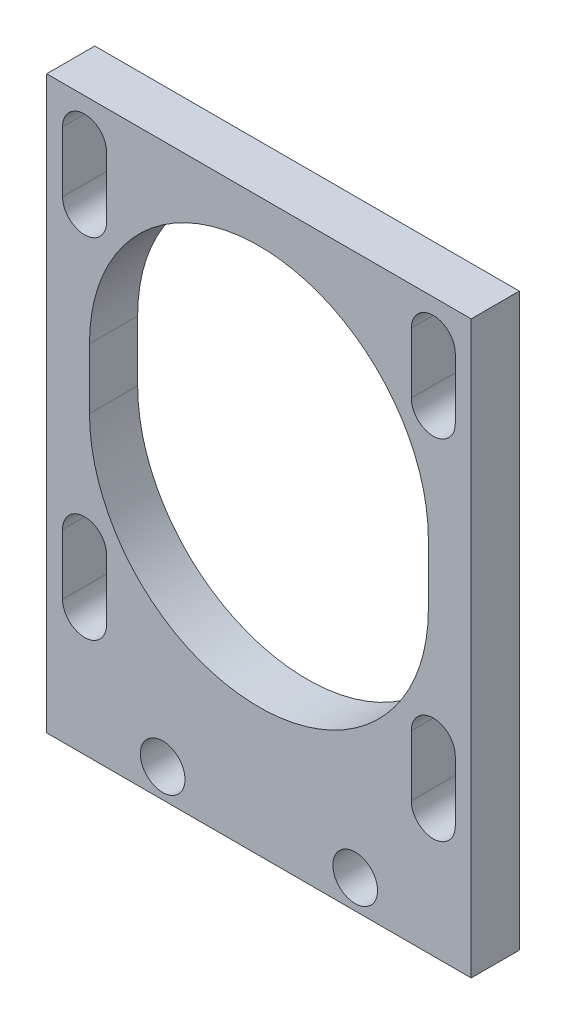
from build123d import *

# Parameters (mm, degrees)
SKETCH1_W                 = 27.99999988
SKETCH1_H                 = 28
BOSS_EXTRUDE1_DEPTH       = 3.175
SKETCH6_W                 = 27.99999988
SKETCH6_H                 = 3.175
BOSS_EXTRUDE2_DEPTH       = 38.1
CUT_EXTRUDE3_DEPTH        = 4.175
F_4_CLEARANCE_HOLE1_D     = 2.9464
F_4_CLEARANCE_HOLE1_DEPTH = 12.954
F_4_CLEARANCE_HOLE1_TIP   = 0.885187864
SKETCH10_W                = 27.99999988
SKETCH10_H                = 28.448
CUT_EXTRUDE4_DEPTH        = 4.175


with BuildPart() as part:
    # Sketch1 → Boss-Extrude1 (new body)
    with BuildSketch(Plane.XY):
        Rectangle(SKETCH1_W, SKETCH1_H)
    extrude(amount=BOSS_EXTRUDE1_DEPTH)

    # Sketch6 → Boss-Extrude2 (add)
    with BuildSketch(Plane(origin=(0, 14, 0), x_dir=(1, 0, 0), z_dir=(0, 1, 0))):
        with Locations((0, -1.5875)):
            Rectangle(SKETCH6_W, SKETCH6_H)
    extrude(amount=BOSS_EXTRUDE2_DEPTH)

    # Sketch7 → Cut-Extrude3 (cut, through all)
    with BuildSketch(Plane(origin=(0, 0, 0), x_dir=(-1, 0, 0), z_dir=(0, 0, -1))):
        with BuildLine():
            Line((-12.94999994, 45.6), (-12.94999994, 49.6))
            ThreePointArc((-12.94999994, 49.6), (-11.49999994, 51.05), (-10.04999994, 49.6))
            Line((-10.04999994, 49.6), (-10.04999994, 45.6))
            ThreePointArc((-10.04999994, 45.6), (-11.49999994, 44.15), (-12.94999994, 45.6))
        make_face()
        with BuildLine():
            Line((10.05000006, 45.6), (10.05000006, 49.6))
            ThreePointArc((10.05000006, 49.6), (11.50000006, 51.05), (12.95000006, 49.6))
            Line((12.95000006, 49.6), (12.95000006, 45.6))
            ThreePointArc((12.95000006, 45.6), (11.50000006, 44.15), (10.05000006, 45.6))
        make_face()
        with BuildLine():
            Line((-12.94999994, 22.6), (-12.94999994, 26.6))
            ThreePointArc((-12.94999994, 26.6), (-11.49999994, 28.05), (-10.04999994, 26.6))
            Line((-10.04999994, 26.6), (-10.04999994, 22.6))
            ThreePointArc((-10.04999994, 22.6), (-11.49999994, 21.15), (-12.94999994, 22.6))
        make_face()
        with BuildLine():
            Line((10.05000006, 22.6), (10.05000006, 26.6))
            ThreePointArc((10.05000006, 26.6), (11.50000006, 28.05), (12.95000006, 26.6))
            Line((12.95000006, 26.6), (12.95000006, 22.6))
            ThreePointArc((12.95000006, 22.6), (11.50000006, 21.15), (10.05000006, 22.6))
        make_face()
        with BuildLine():
            Line((-11.176, 34.1), (-11.176, 38.1))
            ThreePointArc((-11.176, 38.1), (0, 49.276), (11.176, 38.1))
            Line((11.176, 38.1), (11.176, 34.1))
            ThreePointArc((11.176, 34.1), (0, 22.924), (-11.176, 34.1))
        make_face()
    extrude(amount=-CUT_EXTRUDE3_DEPTH, mode=Mode.SUBTRACT)

    # #4 Clearance Hole1
    with Locations(Plane(origin=(0, 0, 0), x_dir=(-1, 0, 0), z_dir=(0, 0, -1))):
        with Locations((-6.35, 16.345772244), (6.35, 16.345772244)):
            Hole(F_4_CLEARANCE_HOLE1_D / 2, depth=F_4_CLEARANCE_HOLE1_DEPTH)
            with Locations((0, 0, -(F_4_CLEARANCE_HOLE1_DEPTH + F_4_CLEARANCE_HOLE1_TIP / 2))):  # 118° drill point
                Cone(0, F_4_CLEARANCE_HOLE1_D / 2, F_4_CLEARANCE_HOLE1_TIP, mode=Mode.SUBTRACT)

    # Sketch10 → Cut-Extrude4 (cut, through all)
    with BuildSketch(Plane(origin=(0, 0, 0), x_dir=(-1, 0, 0), z_dir=(0, 0, -1))):
        with Locations((0, 0.224)):
            Rectangle(SKETCH10_W, SKETCH10_H)
    extrude(amount=-CUT_EXTRUDE4_DEPTH, mode=Mode.SUBTRACT)


solid = part.part
